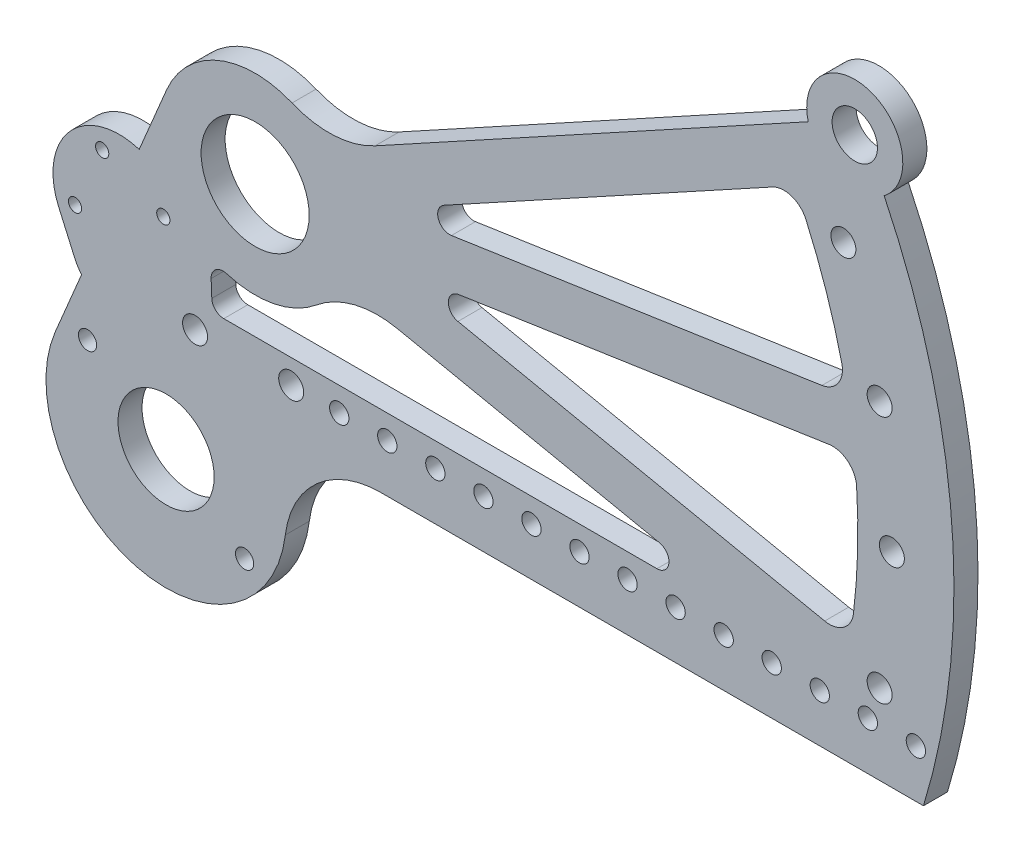
from build123d import *

# Parameters (mm, degrees)
MODEL_R             = 2.413
MODEL_R_2           = 12.7
MODEL_R_3           = 14.281149998
MODEL_R_4           = 3.302
MODEL_R_5           = 2.5527
MODEL_R_6           = 6.00075
MODEL_R_7           = 1.6
MODEL_R_8           = 6.599999999
BOSS_EXTRUDE2_DEPTH = 6.35
BOSS_EXTRUDE3_DEPTH = 6.35
CUT_EXTRUDE2_DEPTH  = 7.35
SKETCH3_R           = 1.75
BOSS_EXTRUDE4_DEPTH = 6.35
SKETCH3_6_R         = 1.75
CUT_EXTRUDE3_DEPTH  = 7.35
BOSS_EXTRUDE5_DEPTH = 6.35
SKETCH9_R           = 5.9944
CUT_EXTRUDE4_DEPTH  = 7.35


with BuildPart() as part:
    # Model → Boss-Extrude2 (new body)
    with BuildSketch(Plane.XY):
        with BuildLine():
            Line((33.194381935, -53.975), (176.626960261, -53.975))
            ThreePointArc((176.626960261, -53.975), (179.801405862, -42.211824955), (182.193350463, -30.264942807))
            ThreePointArc((182.193350463, -30.264942807), (183.829791454, 17.804254832), (172.999114376, 64.665989059))
            ThreePointArc((172.999114376, 64.665989059), (172.041022004, 67.851130989), (171.507342233, 71.134156425))
            Line((171.507342233, 71.134156425), (168.283057515, 104.748950069))
            ThreePointArc((168.283057515, 104.748950069), (153.768177108, 120.335666132), (134.949478429, 110.361496948))
            Line((134.949478429, 110.361496948), (120.644399952, 79.107921201))
            ThreePointArc((120.644399952, 79.107921201), (116.145567058, 72.378282822), (109.757890395, 67.405847105))
            Line((109.757890395, 67.405847105), (31.721738278, 24.629886736))
            ThreePointArc((31.721738278, 24.629886736), (20.873181942, 21.53956394), (9.756276385, 23.451547307))
            ThreePointArc((9.756276385, 23.451547307), (-9.646239085, 23.497022608), (-23.420042255, 9.831664186))
            Line((-23.420042255, 9.831664186), (-52.812443226, -60.184078795))
            ThreePointArc((-52.812443226, -60.184078795), (-31.676825474, -103.162616273), (7.980260895, -76.307737346))
            ThreePointArc((7.980260895, -76.307737346), (16.353189451, -60.360946363), (33.194381935, -53.975))
        make_face()
        with Locations((-2.78154477, -87.114522117)):
            Circle(MODEL_R, mode=Mode.SUBTRACT)
        with Locations((-44.293236039, -57.832795939)):
            Circle(MODEL_R, mode=Mode.SUBTRACT)
        with Locations((-23.537390405, -72.473659028)):
            Circle(MODEL_R_2, mode=Mode.SUBTRACT)
        with BuildLine():
            ThreePointArc((-12.841593176, -42.57947194), (-19.109154707, -40.609081586), (-12.573, -41.275))
            ThreePointArc((-12.573, -41.275), (-12.640845293, -41.940918414), (-12.841593176, -42.57947194))
        make_face(mode=Mode.SUBTRACT)
        with Locations((2e-09, -1e-09)):
            Circle(MODEL_R_3, mode=Mode.SUBTRACT)
        with Locations((9.525, -41.275)):
            Circle(MODEL_R_4, mode=Mode.SUBTRACT)
        with Locations((22.225, -41.275)):
            Circle(MODEL_R_5, mode=Mode.SUBTRACT)
        with Locations((34.925, -41.275)):
            Circle(MODEL_R_5, mode=Mode.SUBTRACT)
        with Locations((47.625, -41.275)):
            Circle(MODEL_R_5, mode=Mode.SUBTRACT)
        with Locations((60.325, -41.275)):
            Circle(MODEL_R_5, mode=Mode.SUBTRACT)
        with BuildLine():
            ThreePointArc((16.191119841, -19.570580939), (26.262071613, -14.489518063), (37.54006963, -14.270359917))
            Line((37.54006963, -14.270359917), (106.835310384, -28.641149755))
            ThreePointArc((106.835310384, -28.641149755), (109.349000903, -32.074056686), (106.19058164, -34.925))
            Line((106.19058164, -34.925), (-8.284075387, -34.925))
            ThreePointArc((-8.284075387, -34.925), (-10.484598164, -34.038738628), (-11.456624352, -31.874731974))
            Line((-11.456624352, -31.874731974), (-11.631809955, -27.418898539))
            ThreePointArc((-11.631809955, -27.418898539), (-10.39277622, -24.775805221), (-7.519343102, -24.26148139))
            ThreePointArc((-7.519343102, -24.26148139), (4.929611011, -24.917041062), (16.191119841, -19.570580939))
        make_face(mode=Mode.SUBTRACT)
        with Locations((73.025, -41.275)):
            Circle(MODEL_R_5, mode=Mode.SUBTRACT)
        with Locations((85.725, -41.275)):
            Circle(MODEL_R_5, mode=Mode.SUBTRACT)
        with Locations((98.425, -41.275)):
            Circle(MODEL_R_5, mode=Mode.SUBTRACT)
        with Locations((111.125, -41.275)):
            Circle(MODEL_R_5, mode=Mode.SUBTRACT)
        with Locations((123.825, -41.275)):
            Circle(MODEL_R_5, mode=Mode.SUBTRACT)
        with BuildLine():
            Line((150.525780255, -24.731666411), (53.587874929, -4.628204042))
            ThreePointArc((53.587874929, -4.628204042), (51.058848917, -1.430439454), (53.762941599, 1.62071667))
            Line((53.762941599, 1.62071667), (151.674333159, 16.265377518))
            ThreePointArc((151.674333159, 16.265377518), (156.599060705, 14.928824322), (158.95010909, 10.399819206))
            ThreePointArc((158.95010909, 10.399819206), (159.227492405, -4.460838665), (158.118539501, -19.282657626))
            ThreePointArc((158.118539501, -19.282657626), (155.517613032, -23.672930664), (150.525780255, -24.731666411))
        make_face(mode=Mode.SUBTRACT)
        with Locations((136.525, -41.275)):
            Circle(MODEL_R_5, mode=Mode.SUBTRACT)
        with Locations((149.225, -41.275)):
            Circle(MODEL_R_5, mode=Mode.SUBTRACT)
        with Locations((161.925, -41.275)):
            Circle(MODEL_R_5, mode=Mode.SUBTRACT)
        with Locations((174.625, -41.275)):
            Circle(MODEL_R_5, mode=Mode.SUBTRACT)
        with Locations((165.041643061, -32.828823938)):
            Circle(MODEL_R_4, mode=Mode.SUBTRACT)
        with Locations((168.275000002, -1e-09)):
            Circle(MODEL_R_4, mode=Mode.SUBTRACT)
        with BuildLine():
            Line((149.795684871, 28.825659386), (51.884293311, 14.180998537))
            ThreePointArc((51.884293311, 14.180998537), (48.40578749, 16.307419992), (49.888483051, 20.105219991))
            Line((49.888483051, 20.105219991), (136.7018524, 67.692461879))
            ThreePointArc((136.7018524, 67.692461879), (141.785005521, 68.14064733), (145.556679438, 64.703527647))
            ThreePointArc((145.556679438, 64.703527647), (150.953895829, 50.854840016), (155.036811216, 36.563377676))
            ThreePointArc((155.036811216, 36.563377676), (154.113819123, 31.54467252), (149.795684871, 28.825659386))
        make_face(mode=Mode.SUBTRACT)
        with Locations((165.041643061, 32.828823937)):
            Circle(MODEL_R_4, mode=Mode.SUBTRACT)
        with Locations((143.968148324, 91.96125582)):
            Circle(MODEL_R_6, mode=Mode.SUBTRACT)
        with Locations((155.465828334, 64.396054582)):
            Circle(MODEL_R_4, mode=Mode.SUBTRACT)
        with Locations((161.105196874, 87.885715063)):
            Circle(MODEL_R_6, mode=Mode.SUBTRACT)
        with Locations((138.411127855, 104.180489712)):
            Circle(MODEL_R_7, mode=Mode.SUBTRACT)
        with Locations((150.86241233, 103.077985772)):
            Circle(MODEL_R_8, mode=Mode.SUBTRACT)
        with Locations((151.96491627, 115.529270247)):
            Circle(MODEL_R_7, mode=Mode.SUBTRACT)
        with Locations((163.313696806, 101.975481832)):
            Circle(MODEL_R_7, mode=Mode.SUBTRACT)
    extrude(amount=BOSS_EXTRUDE2_DEPTH)

    # Sketch2 → Boss-Extrude3 (add, through all)
    with BuildSketch(Plane.XY.offset(6.35)):
        with BuildLine():
            Line((143.625048634, 85.970322406), (149.20311028, 89.027968606))
            ThreePointArc((149.20311028, 89.027968606), (146.8525684, 86.699210458), (143.625048634, 85.970322406))
        make_face()
        with BuildLine():
            ThreePointArc((164.878362916, 83.219644063), (162.13420828, 88.447058862), (159.224374167, 93.584092596))
            ThreePointArc((159.224374167, 93.584092596), (155.837304584, 85.011987277), (164.878362916, 83.219644063))
        make_face()
    extrude(amount=-BOSS_EXTRUDE3_DEPTH)

    # Sketch2_3 → Cut-Extrude2 (cut, through all)
    with BuildSketch(Plane.XY.offset(6.35)):
        with BuildLine():
            ThreePointArc((159.224374167, 93.584092596), (159.015682677, 93.938258333), (158.80620341, 94.291958693))
            Line((158.80620341, 94.291958693), (149.20311028, 89.027968606))
            Line((149.20311028, 89.027968606), (143.625048634, 85.970322406))
            Line((143.625048634, 85.970322406), (109.757890395, 67.405847105))
            ThreePointArc((109.757890395, 67.405847105), (116.145567058, 72.378282822), (120.644399952, 79.107921201))
            Line((120.644399952, 79.107921201), (134.949478429, 110.361496948))
            ThreePointArc((134.949478429, 110.361496948), (153.768177108, 120.335666132), (168.283057515, 104.748950069))
            Line((168.283057515, 104.748950069), (171.507342233, 71.134156425))
            ThreePointArc((171.507342233, 71.134156425), (172.041022004, 67.851130989), (172.999114376, 64.665989059))
            ThreePointArc((172.999114376, 64.665989059), (166.739844557, 79.424227745), (159.224374167, 93.584092596))
        make_face()
    extrude(amount=-CUT_EXTRUDE2_DEPTH, mode=Mode.SUBTRACT)

    # Sketch3 → Boss-Extrude4 (add, through all)
    with BuildSketch(Plane(origin=(0, 0, 0), x_dir=(-1, 0, 0), z_dir=(0, 0, -1))):
        with Locations((24.263890272, -19.571729998)):
            Circle(SKETCH3_R)
        with BuildLine():
            Line((47.569931866, -41.013247954), (51.934565947, -31.139666326))
            ThreePointArc((51.934565947, -31.139666326), (48.962006062, -12.385946654), (30.645740354, -7.380696976))
            Line((30.645740354, -7.380696976), (45.859161931, -43.620642669))
            ThreePointArc((45.859161931, -43.620642669), (46.821980785, -42.387435085), (47.569931866, -41.013247954))
        make_face()
        with Locations((40.421189912, -12.399445261)):
            Circle(SKETCH3_R, mode=Mode.SUBTRACT)
        with Locations((47.593474649, -28.556744901)):
            Circle(SKETCH3_R, mode=Mode.SUBTRACT)
    extrude(amount=-BOSS_EXTRUDE4_DEPTH)

    # Sketch3_6 → Cut-Extrude3 (cut, through all)
    with BuildSketch(Plane(origin=(0, 0, 0), x_dir=(-1, 0, 0), z_dir=(0, 0, -1))):
        with Locations((24.263890272, -19.571729998)):
            Circle(SKETCH3_6_R)
    extrude(amount=-CUT_EXTRUDE3_DEPTH, mode=Mode.SUBTRACT)

    # Sketch8 → Boss-Extrude5 (add, through all)
    with BuildSketch(Plane(origin=(0, 0, 0), x_dir=(-1, 0, 0), z_dir=(0, 0, -1))):
        with BuildLine():
            Line((-158.80620341, 94.291958693), (-146.170088384, 87.365400413))
            ThreePointArc((-146.170088384, 87.365400413), (-162.606044593, 102.518063532), (-166.242121917, 80.460801739))
            ThreePointArc((-166.242121917, 80.460801739), (-162.671228787, 87.455446032), (-158.80620341, 94.291958693))
        make_face()
    extrude(amount=-BOSS_EXTRUDE5_DEPTH)

    # Sketch9 → Cut-Extrude4 (cut, through all)
    with BuildSketch(Plane(origin=(0, 0, 0), x_dir=(-1, 0, 0), z_dir=(0, 0, -1))):
        with Locations((-158.474943349, 90.50873372)):
            Circle(SKETCH9_R)
    extrude(amount=-CUT_EXTRUDE4_DEPTH, mode=Mode.SUBTRACT)


solid = part.part
